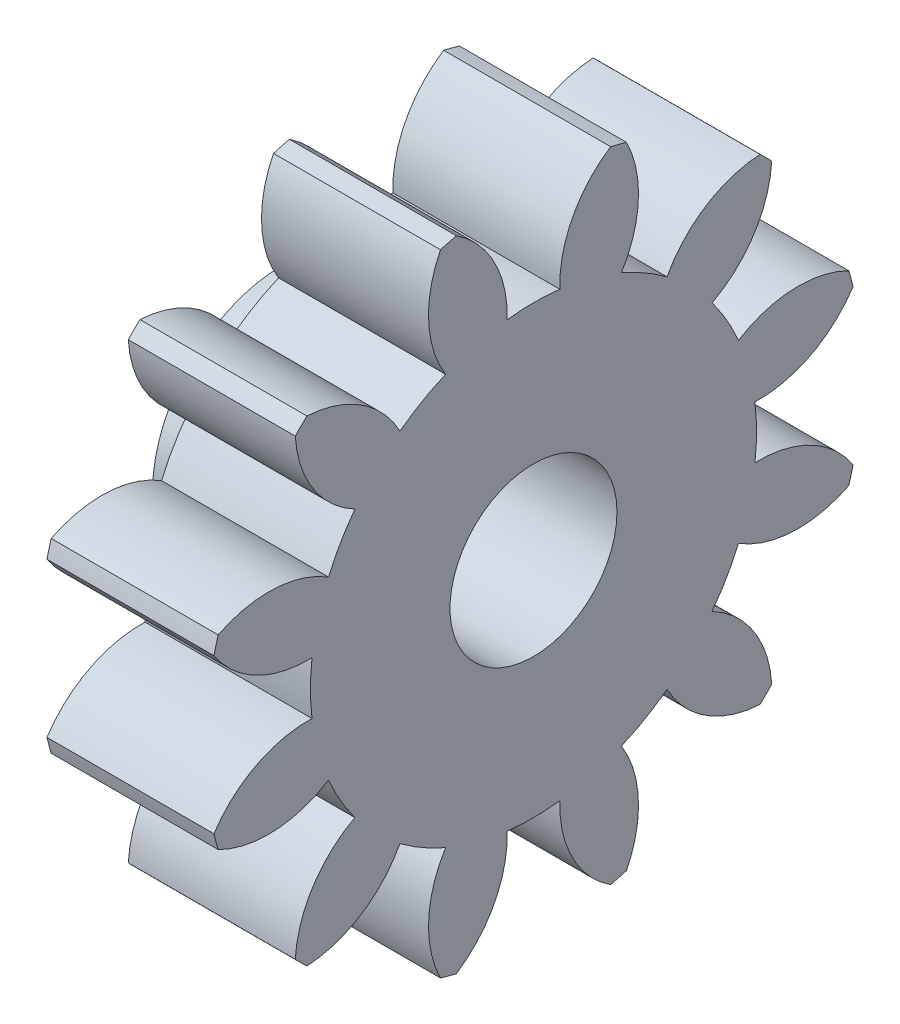
from build123d import *

# Parameters (mm, degrees)
BASPROSKE_W         = 4
BASPROSKE_H         = 7.875
TOOTHCUT_DEPTH      = 12.833480046
TEETHCUTS_COUNT     = 12
TEETHCUTS_ANGLE     = 330
BORSKE_R            = 1
BORE_DEPTH          = 50.0000508
SKETCH1_R           = 3.125
SKETCH1_R_2         = 2.125
BOSS_EXTRUDE1_DEPTH = 2
SKETCH2_R           = 2
CUT_EXTRUDE1_DEPTH  = 3


with BuildPart() as part:
    # BasProSke → Base-Revolve (revolve)
    with BuildSketch(Plane(origin=(0, 0, 0), x_dir=(1, 0, 0), z_dir=(0, 1, 0)), mode=Mode.PRIVATE) as base_revolve_sk:
        with Locations((2, 3.9375)):
            Rectangle(BASPROSKE_W, BASPROSKE_H)
    revolve(base_revolve_sk.sketch.rotate(Axis((-10, 0, 0), (1, 0, 0)), 180), axis=Axis((-10, 0, 0), (1, 0, 0)))

    # TooCutSke → ToothCut (cut, through all)
    with BuildSketch(Plane(origin=(0, 0, 0), x_dir=(0, 0, -1), z_dir=(1, 0, 0))):
        with BuildLine():
            ThreePointArc((0.631439839, 5.305305014), (0, 5.34275), (-0.631439839, 5.305305014))
            ThreePointArc((-0.631439839, 5.305305014), (-0.93992237, 6.654932089), (-1.876748184, 7.674251521))
            ThreePointArc((-1.876748184, 7.674251521), (0, 7.9004), (1.876748184, 7.674251521))
            ThreePointArc((1.876748184, 7.674251521), (0.93992237, 6.654932089), (0.631439839, 5.305305014))
        make_face()
    toothcut = extrude(amount=TOOTHCUT_DEPTH, mode=Mode.SUBTRACT)

    # TeethCuts: ToothCut ×12 about axis
    teethcuts_axis = Axis((-10, 0, 0), (1, 0, 0))
    for i in range(1, TEETHCUTS_COUNT):
        add(toothcut.rotate(teethcuts_axis, i * TEETHCUTS_ANGLE / (TEETHCUTS_COUNT - 1)), mode=Mode.SUBTRACT)

    # BorSke → Bore (cut, symmetric)
    with BuildSketch(Plane(origin=(0, 0, 0), x_dir=(0, 0, -1), z_dir=(1, 0, 0))):
        with Locations(Location((0, 0, 0), (0, 0, 180))):
            Circle(BORSKE_R)
    extrude(amount=BORE_DEPTH, both=True, mode=Mode.SUBTRACT)

    # Sketch1 → Boss-Extrude1 (add)
    with BuildSketch(Plane.ZY):
        with Locations(Location((0, 0, 0), (0, 0, 180))):
            Circle(SKETCH1_R)
        Circle(SKETCH1_R_2, mode=Mode.SUBTRACT)
    extrude(amount=BOSS_EXTRUDE1_DEPTH)

    # Sketch2 → Cut-Extrude1 (cut)
    with BuildSketch(Plane(origin=(4, 0, 0), x_dir=(0, 0, -1), z_dir=(1, 0, 0))):
        Circle(SKETCH2_R)
    extrude(amount=-CUT_EXTRUDE1_DEPTH, mode=Mode.SUBTRACT)


solid = part.part
